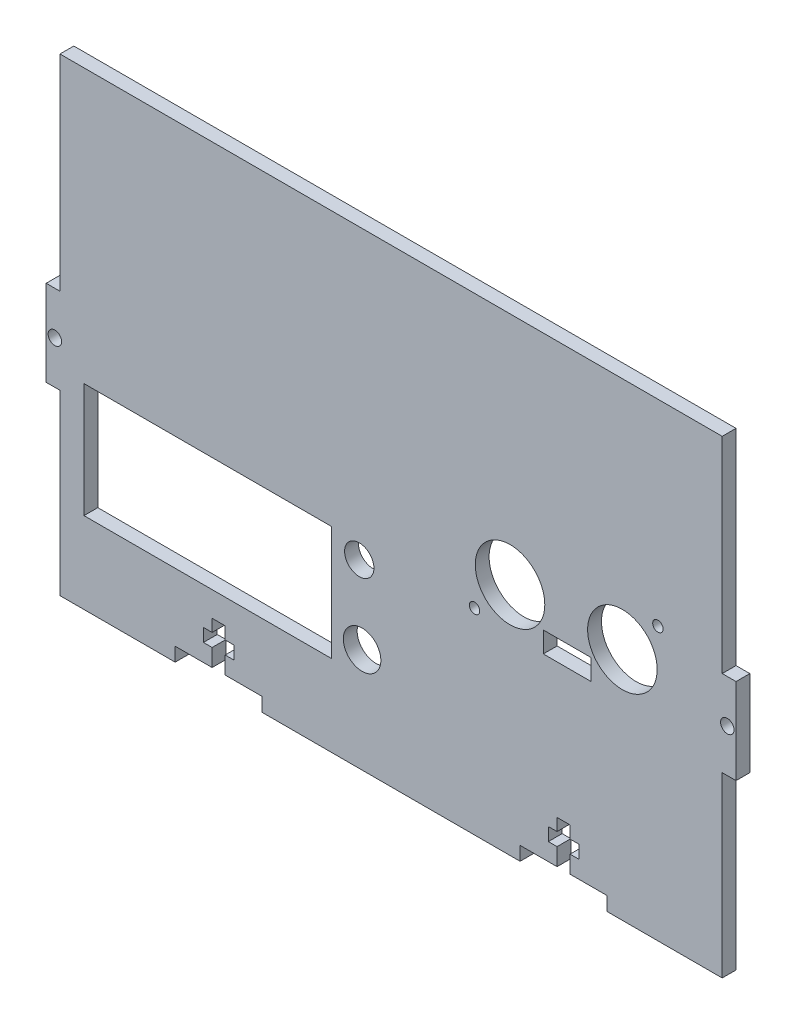
from build123d import *

# Parameters (mm, degrees)
SKETCH2_W                = 158.76
SKETCH2_H                = 107.96
BOSS_EXTRUDE2_DEPTH      = 3.18
CUT_EXTRUDE1_START       = -4.18
CUT_EXTRUDE1_DEPTH       = 5.18
CUT_EXTRUDE2_START       = -4.18
SKETCH4_3_W              = 20
SKETCH4_3_H              = 3.18
CUT_EXTRUDE2_DEPTH       = 5.18
CUT_EXTRUDE3_START       = -4.18
SKETCH7_W                = 3.18
SKETCH7_H                = 47.285
CUT_EXTRUDE3_DEPTH       = 5.18
MIRROR8_START            = -4.18
MIRROR8_COPY_1_DEPTH     = 5.18
MIRROR8_COPY_2_SKETCH_W  = 20
MIRROR8_COPY_2_SKETCH_H  = 3.18
MIRROR8_COPY_2_DEPTH     = 5.18
CUT_EXTRUDE5_START       = -4.18
SKETCH9_W                = 3.18
SKETCH9_H                = 40.925
CUT_EXTRUDE5_DEPTH       = 5.18
CUT_EXTRUDE6_START       = -4.18
SKETCH10_R               = 1.55
CUT_EXTRUDE6_DEPTH       = 5.18
SKETCH11_W               = 57.007059908
SKETCH11_H               = 26.318772473
CUT_EXTRUDE7_DEPTH       = 1
CUT_EXTRUDE7_DEPTH_BACK  = 4.18
SKETCH13_R               = 3.375
CUT_EXTRUDE8_DEPTH       = 1
CUT_EXTRUDE8_DEPTH_BACK  = 4.18
SKETCH14_R               = 8
CUT_EXTRUDE9_DEPTH       = 1
CUT_EXTRUDE9_DEPTH_BACK  = 4.18
SKETCH15_R               = 4.32
CUT_EXTRUDE10_DEPTH      = 1
CUT_EXTRUDE10_DEPTH_BACK = 4.18
SKETCH16_W               = 20.486989201
SKETCH16_H               = 13.990291519
BOSS_EXTRUDE3_DEPTH      = 3.18
SKETCH17_W               = 20.034045414
SKETCH17_H               = 13
BOSS_EXTRUDE4_DEPTH      = 3.18
SKETCH18_W               = 11
SKETCH18_H               = 4.778140913
CUT_EXTRUDE11_DEPTH      = 1
CUT_EXTRUDE11_DEPTH_BACK = 4.18
SKETCH20_R               = 1.2
CUT_EXTRUDE12_DEPTH      = 1
CUT_EXTRUDE12_DEPTH_BACK = 4.18


with BuildPart() as part:
    # Sketch2 → Boss-Extrude2 (new body)
    with BuildSketch(Plane.XY):
        Rectangle(SKETCH2_W, SKETCH2_H)
    extrude(amount=BOSS_EXTRUDE2_DEPTH)

    # Sketch4 → Cut-Extrude1 (cut)
    with BuildSketch(Plane.XY.offset(3.18).offset(CUT_EXTRUDE1_START)):
        Polygon((41.19, 46.8), (43.19, 46.8), (43.19, 43.8), (41.19, 43.8), (41.19, 40.98), (38.19, 40.98), (38.19, 43.8), (36.19, 43.8), (36.19, 46.8), (38.19, 46.8), (38.19, 50.8), (41.19, 50.8), align=None)
    cut_extrude1 = extrude(amount=CUT_EXTRUDE1_DEPTH, mode=Mode.SUBTRACT)

    # Sketch4_3 → Cut-Extrude2 (cut)
    with BuildSketch(Plane.XY.offset(3.18).offset(CUT_EXTRUDE2_START)):
        Polygon((41.19, 46.8), (43.19, 46.8), (43.19, 43.8), (41.19, 43.8), (41.19, 40.98), (38.19, 40.98), (38.19, 43.8), (36.19, 43.8), (36.19, 46.8), (38.19, 46.8), (38.19, 50.8), (41.19, 50.8), align=None)
        with Locations((39.69, 52.39)):
            Rectangle(SKETCH4_3_W, SKETCH4_3_H)
    cut_extrude2 = extrude(amount=CUT_EXTRUDE2_DEPTH, mode=Mode.SUBTRACT)

    # Mirror1: Cut-Extrude1, Cut-Extrude2 across plane
    add(cut_extrude1.mirror(Plane(origin=(0, 0, 0), x_dir=(0, 0, 1), z_dir=(1, 0, 0))), mode=Mode.SUBTRACT)
    add(cut_extrude2.mirror(Plane(origin=(0, 0, 0), x_dir=(0, 0, 1), z_dir=(1, 0, 0))), mode=Mode.SUBTRACT)

    # Sketch7 → Cut-Extrude3 (cut)
    with BuildSketch(Plane.XY.offset(3.18).offset(CUT_EXTRUDE3_START)):
        with Locations((-77.79, 30.3375)):
            Rectangle(SKETCH7_W, SKETCH7_H)
    cut_extrude3 = extrude(amount=CUT_EXTRUDE3_DEPTH, mode=Mode.SUBTRACT)

    # Mirror8: Cut-Extrude1, Cut-Extrude2 across plane
    add(cut_extrude1.mirror(Plane.ZX), mode=Mode.SUBTRACT)
    add(cut_extrude2.mirror(Plane.ZX), mode=Mode.SUBTRACT)

    # Mirror8 copy 1 sketch → Mirror8 copy 1 (cut)
    with BuildSketch(Plane(origin=(0, 0, 3.18), x_dir=(-1, 0, 0), z_dir=(0, 0, 1)).offset(MIRROR8_START)):
        Polygon((41.19, 46.8), (43.19, 46.8), (43.19, 43.8), (41.19, 43.8), (41.19, 40.98), (38.19, 40.98), (38.19, 43.8), (36.19, 43.8), (36.19, 46.8), (38.19, 46.8), (38.19, 50.8), (41.19, 50.8), align=None)
    extrude(amount=MIRROR8_COPY_1_DEPTH, mode=Mode.SUBTRACT)

    # Mirror8 copy 2 sketch → Mirror8 copy 2 (cut)
    with BuildSketch(Plane(origin=(0, 0, 3.18), x_dir=(-1, 0, 0), z_dir=(0, 0, 1)).offset(MIRROR8_START)):
        Polygon((41.19, 46.8), (43.19, 46.8), (43.19, 43.8), (41.19, 43.8), (41.19, 40.98), (38.19, 40.98), (38.19, 43.8), (36.19, 43.8), (36.19, 46.8), (38.19, 46.8), (38.19, 50.8), (41.19, 50.8), align=None)
        with Locations((39.69, 52.39)):
            Rectangle(MIRROR8_COPY_2_SKETCH_W, MIRROR8_COPY_2_SKETCH_H)
    extrude(amount=MIRROR8_COPY_2_DEPTH, mode=Mode.SUBTRACT)

    # Mirror10: Cut-Extrude3 across plane
    add(cut_extrude3.mirror(Plane(origin=(0, 0, 0), x_dir=(0, 0, 1), z_dir=(1, 0, 0))), mode=Mode.SUBTRACT)

    # Sketch9 → Cut-Extrude5 (cut)
    with BuildSketch(Plane.XY.offset(3.18).offset(CUT_EXTRUDE5_START)):
        with Locations((-77.79, -33.5175)):
            Rectangle(SKETCH9_W, SKETCH9_H)
    cut_extrude5 = extrude(amount=CUT_EXTRUDE5_DEPTH, mode=Mode.SUBTRACT)

    # Mirror11: Cut-Extrude5 across plane
    add(cut_extrude5.mirror(Plane(origin=(0, 0, 0), x_dir=(0, 0, 1), z_dir=(1, 0, 0))), mode=Mode.SUBTRACT)

    # Sketch10 → Cut-Extrude6 (cut)
    with BuildSketch(Plane.XY.offset(3.18).offset(CUT_EXTRUDE6_START)):
        with Locations((-77.38, -3.18)):
            Circle(SKETCH10_R)
    cut_extrude6 = extrude(amount=CUT_EXTRUDE6_DEPTH, mode=Mode.SUBTRACT)

    # Mirror12: Cut-Extrude6 across plane
    add(cut_extrude6.mirror(Plane(origin=(0, 0, 0), x_dir=(0, 0, 1), z_dir=(1, 0, 0))), mode=Mode.SUBTRACT)

    # Sketch11 → Cut-Extrude7 (cut, two sides)
    with BuildSketch(Plane.XY.offset(3.18)) as cut_extrude7_sk:
        with Locations((-42.177993539, -22.106715471)):
            Rectangle(SKETCH11_W, SKETCH11_H)
    extrude(amount=CUT_EXTRUDE7_DEPTH, mode=Mode.SUBTRACT)
    extrude(cut_extrude7_sk.sketch, amount=-CUT_EXTRUDE7_DEPTH_BACK, mode=Mode.SUBTRACT)

    # Sketch13 → Cut-Extrude8 (cut, two sides)
    with BuildSketch(Plane.XY.offset(3.18)) as cut_extrude8_sk:
        with Locations((-7.324463585, -12.377329235)):
            Circle(SKETCH13_R)
    extrude(amount=CUT_EXTRUDE8_DEPTH, mode=Mode.SUBTRACT)
    extrude(cut_extrude8_sk.sketch, amount=-CUT_EXTRUDE8_DEPTH_BACK, mode=Mode.SUBTRACT)

    # Sketch14 → Cut-Extrude9 (cut, two sides)
    with BuildSketch(Plane.XY.offset(3.18)) as cut_extrude9_sk:
        with Locations((27.372978977, 0)):
            Circle(SKETCH14_R)
        with Locations((53.232978977, 0)):
            Circle(SKETCH14_R)
    extrude(amount=CUT_EXTRUDE9_DEPTH, mode=Mode.SUBTRACT)
    extrude(cut_extrude9_sk.sketch, amount=-CUT_EXTRUDE9_DEPTH_BACK, mode=Mode.SUBTRACT)

    # Sketch15 → Cut-Extrude10 (cut, two sides)
    with BuildSketch(Plane.XY.offset(3.18)) as cut_extrude10_sk:
        with Locations((-6.674463585, -29.98)):
            Circle(SKETCH15_R)
    extrude(amount=CUT_EXTRUDE10_DEPTH, mode=Mode.SUBTRACT)
    extrude(cut_extrude10_sk.sketch, amount=-CUT_EXTRUDE10_DEPTH_BACK, mode=Mode.SUBTRACT)

    # Sketch16 → Boss-Extrude3 (add)
    with BuildSketch(Plane.XY.offset(3.18)):
        with Locations((-39.4465054, 46.98485424)):
            Rectangle(SKETCH16_W, SKETCH16_H)
    extrude(amount=-BOSS_EXTRUDE3_DEPTH)

    # Sketch17 → Boss-Extrude4 (add)
    with BuildSketch(Plane.XY.offset(3.18)):
        with Locations((39.707022707, 47.48)):
            Rectangle(SKETCH17_W, SKETCH17_H)
    extrude(amount=-BOSS_EXTRUDE4_DEPTH)

    # Sketch18 → Cut-Extrude11 (cut, two sides)
    with BuildSketch(Plane.XY.offset(3.18)) as cut_extrude11_sk:
        with Locations((40.53, -7.590929543)):
            Rectangle(SKETCH18_W, SKETCH18_H)
    extrude(amount=CUT_EXTRUDE11_DEPTH, mode=Mode.SUBTRACT)
    extrude(cut_extrude11_sk.sketch, amount=-CUT_EXTRUDE11_DEPTH_BACK, mode=Mode.SUBTRACT)

    # Sketch20 → Cut-Extrude12 (cut, two sides)
    with BuildSketch(Plane.XY.offset(3.18)) as cut_extrude12_sk:
        with Locations((61.402978977, 8.75)):
            Circle(SKETCH20_R)
        with Locations((19.202978977, -8.75)):
            Circle(SKETCH20_R)
    extrude(amount=CUT_EXTRUDE12_DEPTH, mode=Mode.SUBTRACT)
    extrude(cut_extrude12_sk.sketch, amount=-CUT_EXTRUDE12_DEPTH_BACK, mode=Mode.SUBTRACT)


solid = part.part
